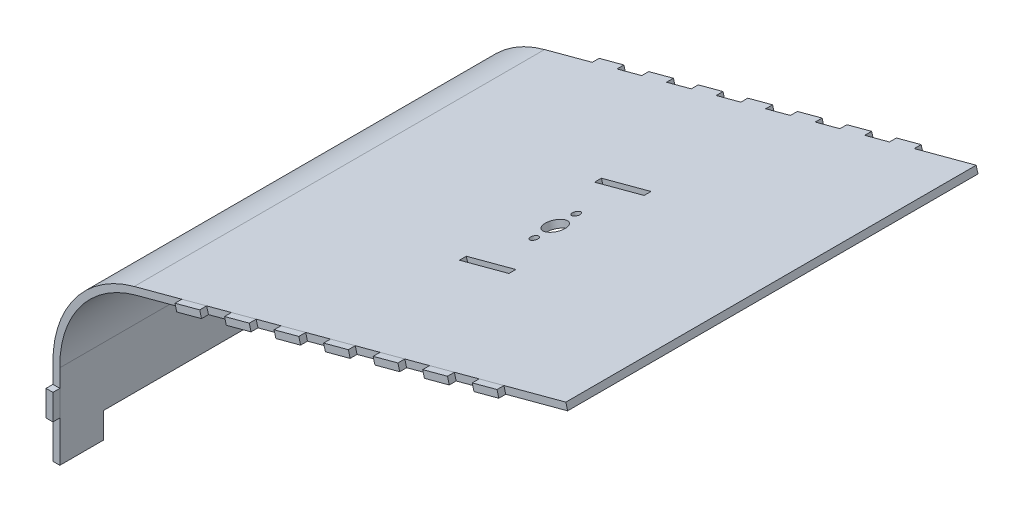
from build123d import *

# Parameters (mm, degrees)
EXTRUDE_THIN1_DEPTH   = 160
SKETCH2_W             = 2.7
SKETCH2_H             = 10
BOSS_EXTRUDE1_DEPTH   = 2.7
BOSS_EXTRUDE1_2_DEPTH = 2.7
BOSS_EXTRUDE1_3_DEPTH = 2.7
BOSS_EXTRUDE1_4_DEPTH = 2.7
BOSS_EXTRUDE1_5_DEPTH = 2.7
BOSS_EXTRUDE1_6_DEPTH = 2.7
BOSS_EXTRUDE1_7_DEPTH = 2.7
BOSS_EXTRUDE1_8_DEPTH = 2.7
SKETCH3_R             = 4
SKETCH3_R_2           = 1.5
SKETCH3_W             = 20
SKETCH3_H             = 2.7
CUT_EXTRUDE1_DEPTH    = 3
SKETCH4_W             = 126
SKETCH4_H             = 10
CUT_EXTRUDE2_DEPTH    = 3


with BuildPart() as part:
    # Sketch1 → Extrude-Thin1 (new body)
    with BuildSketch(Plane.XY):
        with BuildLine():
            Line((100, 60), (-68.302221487, 14.903555668))
            ThreePointArc((-68.302221487, 14.903555668), (-91.366544651, -0.636913735), (-100, -27.074247963))
            Line((-100, -27.074247963), (-100, -60))
            Line((-100, -60), (-97.3, -60))
            Line((-97.3, -60), (-97.3, -27.053019321))
            ThreePointArc((-97.3, -27.053019321), (-89.218029242, -2.272148948), (-67.603410065, 12.295555937))
            Line((-67.603410065, 12.295555937), (100.698811422, 57.392000269))
            Line((100.698811422, 57.392000269), (100, 60))
        make_face()
    extrude(amount=-EXTRUDE_THIN1_DEPTH)


with BuildPart() as body_2:
    # Sketch2 → Boss-Extrude1 (new body)
    with BuildSketch(Plane.XY):
        with Locations((-98.65, -39)):
            Rectangle(SKETCH2_W, SKETCH2_H)
    boss_extrude1 = extrude(amount=BOSS_EXTRUDE1_DEPTH)


with BuildPart() as body_3:
    # Sketch2 → Boss-Extrude1 2 (new body)
    with BuildSketch(Plane.XY):
        Polygon((-40.059244812, 22.47123846), (-49.718503075, 19.883048009), (-49.019691653, 17.275048278), (-39.36043339, 19.863238729), align=None)
    boss_extrude1_2 = extrude(amount=BOSS_EXTRUDE1_2_DEPTH)


with BuildPart() as body_4:
    # Sketch2 → Boss-Extrude1 3 (new body)
    with BuildSketch(Plane.XY):
        Polygon((-20.740728286, 27.647619362), (-30.399986549, 25.059428911), (-29.701175127, 22.45142918), (-20.041916864, 25.039619631), align=None)
    boss_extrude1_3 = extrude(amount=BOSS_EXTRUDE1_3_DEPTH)


with BuildPart() as body_5:
    # Sketch2 → Boss-Extrude1 4 (new body)
    with BuildSketch(Plane.XY):
        Polygon((-1.42221176, 32.824000264), (-11.081470023, 30.235809813), (-10.382658601, 27.627810082), (-0.723400339, 30.216000533), align=None)
    boss_extrude1_4 = extrude(amount=BOSS_EXTRUDE1_4_DEPTH)


with BuildPart() as body_6:
    # Sketch2 → Boss-Extrude1 5 (new body)
    with BuildSketch(Plane.XY):
        Polygon((17.896304765, 38.000381166), (8.237046503, 35.412190715), (8.935857924, 32.804190984), (18.595116187, 35.392381435), align=None)
    boss_extrude1_5 = extrude(amount=BOSS_EXTRUDE1_5_DEPTH)


with BuildPart() as body_7:
    # Sketch2 → Boss-Extrude1 6 (new body)
    with BuildSketch(Plane.XY):
        Polygon((37.214821291, 43.176762068), (27.555563028, 40.588571617), (28.25437445, 37.980571886), (37.913632713, 40.568762337), align=None)
    boss_extrude1_6 = extrude(amount=BOSS_EXTRUDE1_6_DEPTH)


with BuildPart() as body_8:
    # Sketch2 → Boss-Extrude1 7 (new body)
    with BuildSketch(Plane.XY):
        Polygon((56.533337817, 48.35314297), (46.874079554, 45.764952519), (47.572890976, 43.156952788), (57.232149239, 45.745143239), align=None)
    boss_extrude1_7 = extrude(amount=BOSS_EXTRUDE1_7_DEPTH)


with BuildPart() as body_9:
    # Sketch2 → Boss-Extrude1 8 (new body)
    with BuildSketch(Plane.XY):
        Polygon((75.851854343, 53.529523872), (66.19259608, 50.941333421), (66.891407502, 48.33333369), (76.550665765, 50.921524141), align=None)
    boss_extrude1_8 = extrude(amount=BOSS_EXTRUDE1_8_DEPTH)


with BuildPart() as part_1:
    add(part.part)

    # Mirror1: Boss-Extrude1, Boss-Extrude1 2, Boss-Extrude1 3, Boss-Extrude1 4, Boss-Extrude1 5, Boss-Extrude1 6, Boss-Extrude1 7, Boss-Extrude1 8 across plane
    add(boss_extrude1.mirror(Plane.XY.offset(-80)))
    add(boss_extrude1_2.mirror(Plane.XY.offset(-80)))
    add(boss_extrude1_3.mirror(Plane.XY.offset(-80)))
    add(boss_extrude1_4.mirror(Plane.XY.offset(-80)))
    add(boss_extrude1_5.mirror(Plane.XY.offset(-80)))
    add(boss_extrude1_6.mirror(Plane.XY.offset(-80)))
    add(boss_extrude1_7.mirror(Plane.XY.offset(-80)))
    add(boss_extrude1_8.mirror(Plane.XY.offset(-80)))

    # Sketch3 → Cut-Extrude1 (cut)
    with BuildSketch(Plane(origin=(-7.602458767, 28.372762383, 0), x_dir=(0.965925826, 0.258819045, 0), z_dir=(0.258819045, -0.965925826, 0))):
        with Locations((25.002084828, -80)):
            Circle(SKETCH3_R)
        with Locations((25.002084828, -71.8075)):
            Circle(SKETCH3_R_2)
        with Locations((25.002084828, -88.1925)):
            Circle(SKETCH3_R_2)
        with Locations((25.002084828, -106.35)):
            Rectangle(SKETCH3_W, SKETCH3_H)
        with Locations((25.002084828, -53.65)):
            Rectangle(SKETCH3_W, SKETCH3_H)
    extrude(amount=-CUT_EXTRUDE1_DEPTH, mode=Mode.SUBTRACT)

    # Sketch4 → Cut-Extrude2 (cut)
    with BuildSketch(Plane.ZY.offset(100)):
        with Locations((-80, -55)):
            Rectangle(SKETCH4_W, SKETCH4_H)
    extrude(amount=-CUT_EXTRUDE2_DEPTH, mode=Mode.SUBTRACT)


solid = Compound([body_2.part, body_3.part, body_4.part, body_5.part, body_6.part, body_7.part, body_8.part, body_9.part, part_1.part])
